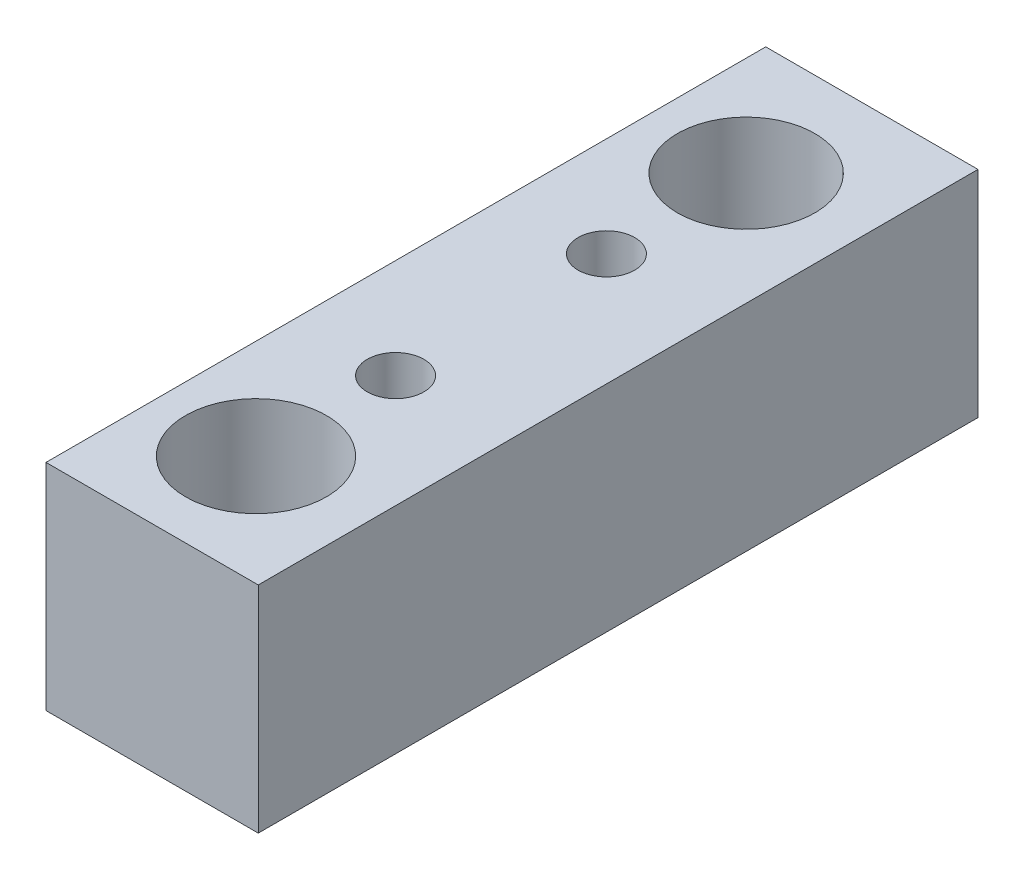
from build123d import *

# Parameters (mm, degrees)
SKETCH1_W           = 203.448651213
SKETCH1_H           = 60.760194486
BOSS_EXTRUDE1_DEPTH = 60
SKETCH2_R           = 19.434497102
SKETCH2_R_2         = 19.923805808
CUT_EXTRUDE2_DEPTH  = 80
SKETCH3_R           = 8
CUT_EXTRUDE3_DEPTH  = 45


with BuildPart() as part:
    # Sketch1 → Boss-Extrude1 (new body)
    with BuildSketch(Plane(origin=(0, 0, 0), x_dir=(0, 0, -1), z_dir=(1, 0, 0))):
        with Locations((-0.196000627, -1.960006274)):
            Rectangle(SKETCH1_W, SKETCH1_H)
    extrude(amount=BOSS_EXTRUDE1_DEPTH)

    # Sketch2 → Cut-Extrude2 (cut)
    with BuildSketch(Plane(origin=(0, 28.420090969, 0), x_dir=(-1, 0, 0), z_dir=(0, 1, 0))):
        with Locations(Location((-28.157475654, -67.835345713, 0), (0, 0, 90))):  # turned: the seam where the file's is
            Circle(SKETCH2_R)
        with Locations(Location((-28.157475654, 70.713811049, 0), (0, 0, 90))):  # turned: the seam where the file's is
            Circle(SKETCH2_R_2)
    extrude(amount=-CUT_EXTRUDE2_DEPTH, mode=Mode.SUBTRACT)

    # Sketch3 → Cut-Extrude3 (cut)
    with BuildSketch(Plane(origin=(0, 28.420090969, 0), x_dir=(1, 0, 0), z_dir=(0, 1, 0))):
        with Locations(Location((28.157475654, 28.339432247, 0), (0, 0, 270))):  # turned: the seam where the file's is
            Circle(SKETCH3_R)
        with Locations(Location((28.157475654, -31.26607036, 0), (0, 0, 270))):  # turned: the seam where the file's is
            Circle(SKETCH3_R)
    extrude(amount=-CUT_EXTRUDE3_DEPTH, mode=Mode.SUBTRACT)


solid = part.part
